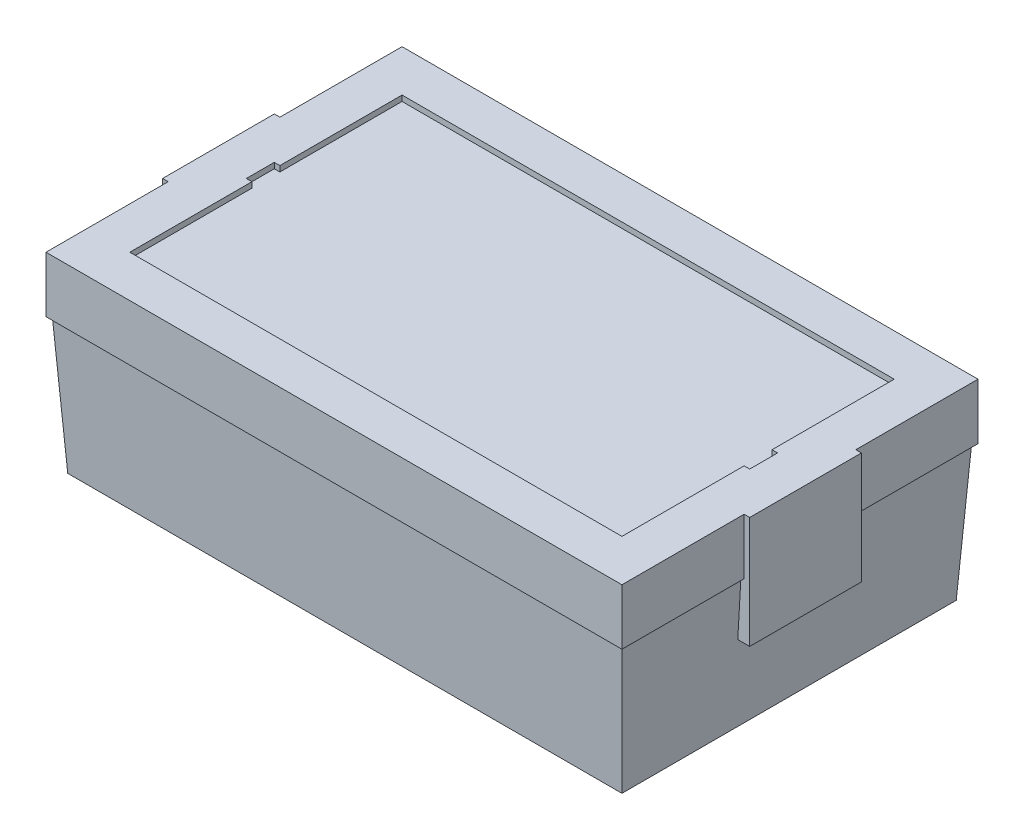
from build123d import *

# Parameters (mm, degrees)
SKETCH1_W           = 218.44
SKETCH1_H           = 139.7
BOSS_EXTRUDE1_DEPTH = 34.29
SKETCH2_W           = 238.44
SKETCH2_H           = 159.7
SKETCH2_W_2         = 198.44
SKETCH2_H_2         = 119.7
CUT_EXTRUDE1_DEPTH  = 172.72
CUT_EXTRUDE1_TAPER  = 3.25
SKETCH3_W           = 206.22850923
SKETCH3_H           = 127.48850923
BOSS_EXTRUDE2_DEPTH = 20
BOSS_EXTRUDE3_START = -20
SKETCH4_W           = 40
SKETCH4_H           = 40
BOSS_EXTRUDE3_DEPTH = 22
CUT_EXTRUDE2_DEPTH  = 2


with BuildPart() as part:
    # Sketch1 → Boss-Extrude1 (new body, symmetric)
    with BuildSketch(Plane(origin=(0, 0, 0), x_dir=(1, 0, 0), z_dir=(0, 1, 0))):
        Rectangle(SKETCH1_W, SKETCH1_H)
    extrude(amount=BOSS_EXTRUDE1_DEPTH, both=True)

    # Sketch2 → Cut-Extrude1 (cut)
    with BuildSketch(Plane.XZ.offset(34.29)):
        Rectangle(SKETCH2_W, SKETCH2_H)
        Rectangle(SKETCH2_W_2, SKETCH2_H_2, mode=Mode.SUBTRACT)
    extrude(amount=-CUT_EXTRUDE1_DEPTH, taper=CUT_EXTRUDE1_TAPER, mode=Mode.SUBTRACT)

    # Sketch3 → Boss-Extrude2 (add)
    with BuildSketch(Plane(origin=(0, 34.29, 0), x_dir=(1, 0, 0), z_dir=(0, 1, 0))):
        Rectangle(SKETCH3_W, SKETCH3_H)
    extrude(amount=-BOSS_EXTRUDE2_DEPTH)

    # Sketch4 → Boss-Extrude3 (add)
    with BuildSketch(Plane(origin=(103.114254615, 0, 0), x_dir=(0, 0, -1), z_dir=(1, 0, 0)).offset(BOSS_EXTRUDE3_START)):
        with Locations((0, 14.29)):
            Rectangle(SKETCH4_W, SKETCH4_H)
    boss_extrude3 = extrude(amount=BOSS_EXTRUDE3_DEPTH)

    # Mirror1: Boss-Extrude3 across plane
    add(boss_extrude3.mirror(Plane(origin=(0, 0, 0), x_dir=(0, 0, 1), z_dir=(1, 0, 0))))

    # Sketch5 → Cut-Extrude2 (cut)
    with BuildSketch(Plane(origin=(0, 34.29, 0), x_dir=(1, 0, 0), z_dir=(0, 1, 0))):
        Polygon((-88.114254615, 48.744254615), (-88.114254615, 5), (-90.114254615, 5), (-90.114254615, -5), (-88.114254615, -5), (-88.114254615, -48.744254615), (88.114254615, -48.744254615), (88.114254615, -5), (90.114254615, -5), (90.114254615, 5), (88.114254615, 5), (88.114254615, 48.744254615), align=None)
    extrude(amount=-CUT_EXTRUDE2_DEPTH, mode=Mode.SUBTRACT)


solid = part.part
